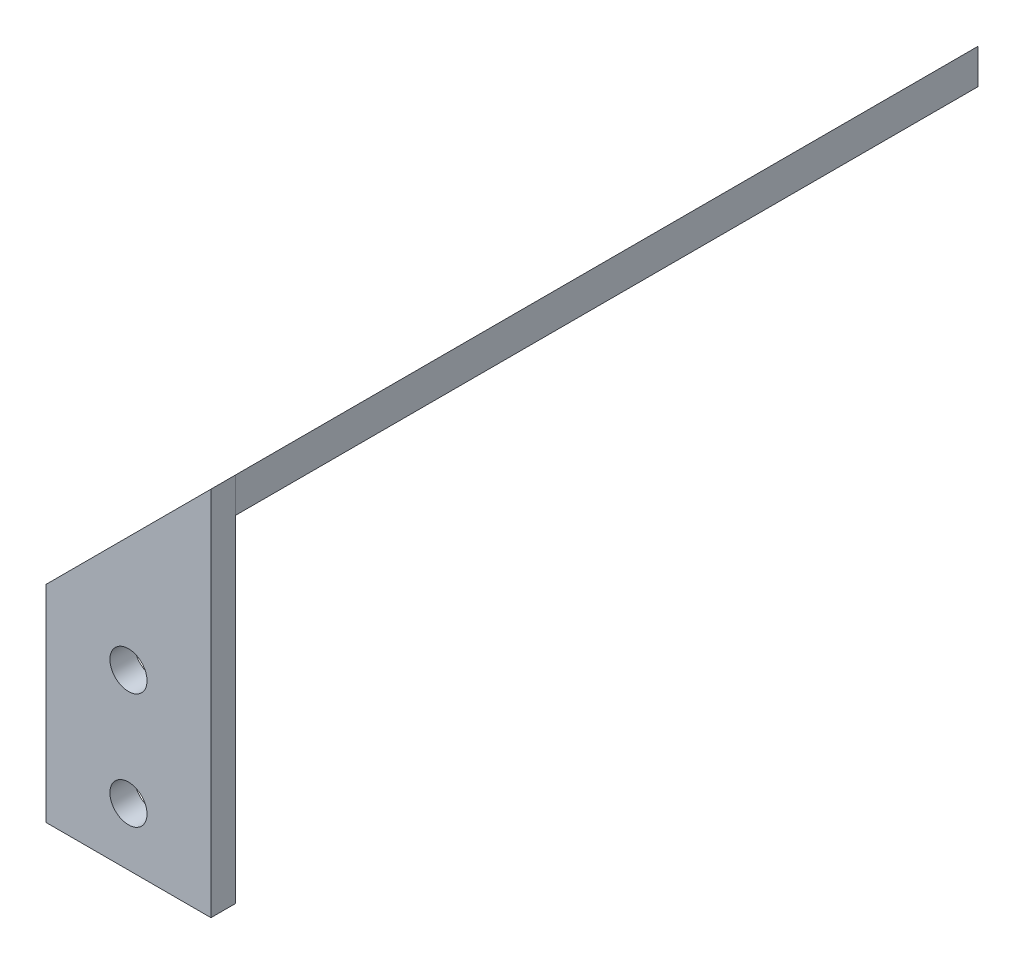
from build123d import *

# Parameters (mm, degrees)
SKETCH1_R           = 2.25
BOSS_EXTRUDE1_DEPTH = 3
SKETCH2_W           = 90
SKETCH2_H           = 28.284271247
SKETCH2_R           = 2.25
BOSS_EXTRUDE2_DEPTH = 3
CUT_EXTRUDE1_DEPTH  = 91


with BuildPart() as part:
    # Sketch1 → Boss-Extrude1 (new body)
    with BuildSketch(Plane.XY):
        Polygon((0, 0), (20, 0), (20, 25), (20, 45), (0, 25), align=None)
        with Locations((10, 7)):
            Circle(SKETCH1_R, mode=Mode.SUBTRACT)
        with Locations((10, 21)):
            Circle(SKETCH1_R, mode=Mode.SUBTRACT)
    extrude(amount=BOSS_EXTRUDE1_DEPTH)


with BuildPart() as body_2:
    # Sketch2 → Boss-Extrude2 (new body)
    with BuildSketch(Plane(origin=(-12.5, 12.5, 0), x_dir=(0, 0, 1), z_dir=(-0.707106781, 0.707106781, 0))):
        with Locations((-45, 31.819805154)):
            Rectangle(SKETCH2_W, SKETCH2_H)
        with Locations((-80, 31.819805153)):
            Circle(SKETCH2_R, mode=Mode.SUBTRACT)
        with Locations((-30, 31.819805153)):
            Circle(SKETCH2_R, mode=Mode.SUBTRACT)
    extrude(amount=-BOSS_EXTRUDE2_DEPTH)

    # Sketch3 → Cut-Extrude1 (cut, through all)
    with BuildSketch(Plane.XY):
        Polygon((22.121320344, 42.878679656), (20, 45), (20, 40.757359313), align=None)
    extrude(amount=-CUT_EXTRUDE1_DEPTH, mode=Mode.SUBTRACT)


solid = Compound([part.part, body_2.part])
